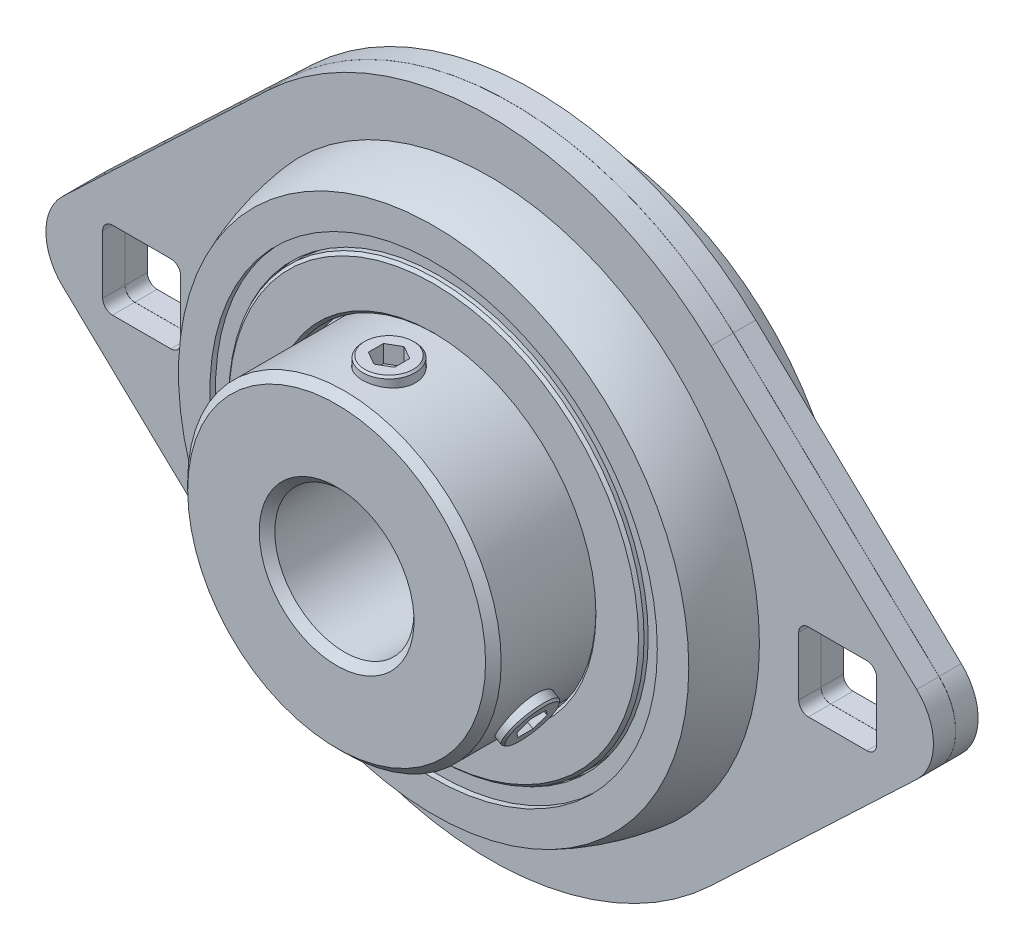
from build123d import *

# Parameters (mm, degrees)
CHAMFER3_SIZE           = 0.254
CHAMFER4_SIZE           = 0.254
CIRPATTERN1_COUNT       = 4
EXTRUDE1_DEPTH          = 2.032
EXTRUDE2_DEPTH          = 2.032
SKETCH6_W               = 7.112
SKETCH6_H               = 7.112
CUT_EXTRUDE1_DEPTH      = 16.99946
CUT_EXTRUDE1_DEPTH_BACK = 8.1501001
FILLET1_R               = 0.889
FILLET2_R               = 0.889
CHAMFER1_SIZE           = 0.7112
SKETCH7_W               = 2.413
SKETCH7_H               = 15.0622
CHAMFER2_SIZE           = 0.1778
CUT_EXTRUDE2_DEPTH      = 1.592865993
CIRPATTERN2_COUNT       = 2
CIRPATTERN2_ANGLE       = 120
CIRPATTERN3_COUNT       = 2
CIRPATTERN3_ANGLE       = 120


with BuildPart() as part:
    # Sketch1 → Revolve1 (revolve)
    with BuildSketch(Plane(origin=(0, 0, 0), x_dir=(0, 0, -1), z_dir=(1, 0, 0))):
        with BuildLine():
            Line((-15.99946, 6.35), (5.99948, 6.35))
            Line((5.99948, 6.35), (5.99948, 14.3002))
            Line((5.99948, 14.3002), (2.676895127, 14.3002))
            ThreePointArc((2.676895127, 14.3002), (0, 13.143865), (-2.676895127, 14.3002))
            Line((-2.676895127, 14.3002), (-15.99946, 14.3002))
            Line((-15.99946, 14.3002), (-15.99946, 6.35))
        make_face()
        with BuildLine():
            Line((0.00508, 29.3751), (0.00508, 22.692456694))
            ThreePointArc((0.00508, 22.692456694), (2.594293192, 22.486042447), (5.1181, 21.872013957))
            Line((5.1181, 21.872013957), (5.1181, 14.5542))
            Line((5.1181, 14.5542), (7.1501, 14.5542))
            Line((7.1501, 14.5542), (7.1501, 18.944888374))
            Line((7.1501, 18.944888374), (6.1341, 18.944888374))
            Line((6.1341, 18.944888374), (6.1341, 19.071888374))
            Line((6.1341, 19.071888374), (6.6421, 19.071888374))
            Line((6.6421, 19.071888374), (6.6421, 20.408451166))
            Line((6.6421, 20.408451166), (7.1501, 20.408451166))
            Line((7.1501, 20.408451166), (7.1501, 23.278359283))
            ThreePointArc((7.1501, 23.278359283), (4.641771595, 24.129812987), (2.03708, 24.611753333))
            Line((2.03708, 24.611753333), (2.03708, 29.3751))
            Line((2.03708, 29.3751), (0.00508, 29.3751))
        make_face()
        with BuildLine():
            Line((-2.03708, 29.3751), (-0.00508, 29.3751))
            Line((-0.00508, 29.3751), (-0.00508, 22.692456694))
            ThreePointArc((-0.00508, 22.692456694), (-2.594293192, 22.486042447), (-5.1181, 21.872013957))
            Line((-5.1181, 21.872013957), (-5.1181, 14.5542))
            Line((-5.1181, 14.5542), (-7.1501, 14.5542))
            Line((-7.1501, 14.5542), (-7.1501, 18.944888374))
            Line((-7.1501, 18.944888374), (-6.1341, 18.944888374))
            Line((-6.1341, 18.944888374), (-6.1341, 19.071888374))
            Line((-6.1341, 19.071888374), (-6.6421, 19.071888374))
            Line((-6.6421, 19.071888374), (-6.6421, 20.408451166))
            Line((-6.6421, 20.408451166), (-7.1501, 20.408451166))
            Line((-7.1501, 20.408451166), (-7.1501, 23.278359283))
            ThreePointArc((-7.1501, 23.278359283), (-4.641771595, 24.129812987), (-2.03708, 24.611753333))
            Line((-2.03708, 24.611753333), (-2.03708, 29.3751))
        make_face()
    revolve(axis=Axis((0, 0, 5.1181), (0, 0, -1)))

    # Chamfer3
    chamfer3_edges = [part.edges().sort_by_distance(p)[0] for p in [
        (0, -18.944888374, 7.1501),
        (0, -14.5542, 7.1501),
    ]]
    chamfer(chamfer3_edges, length=CHAMFER3_SIZE)

    # Chamfer4
    chamfer4_edges = [part.edges().sort_by_distance(p)[0] for p in [
        (0, -14.5542, -7.1501),
        (0, -18.944888374, -7.1501),
    ]]
    chamfer(chamfer4_edges, length=CHAMFER4_SIZE)

    # Sketch4 → Extrude1 (add)
    with BuildSketch(Plane.XY.offset(2.03708)):
        with BuildLine():
            Line((-20.202896864, 21.324620942), (-38.958083746, 3.556))
            ThreePointArc((-38.958083746, 3.556), (-40.4876, 0), (-38.958083746, -3.556))
            Line((-38.958083746, -3.556), (-20.202896864, -21.324620942))
            ThreePointArc((-20.202896864, -21.324620942), (-29.3751, 0), (-20.202896864, 21.324620942))
        make_face()
        with BuildLine():
            Line((20.202896864, -21.324620942), (38.958083746, -3.556))
            ThreePointArc((38.958083746, -3.556), (40.4876, 0), (38.958083746, 3.556))
            Line((38.958083746, 3.556), (20.202896864, 21.324620942))
            ThreePointArc((20.202896864, 21.324620942), (29.3751, 0), (20.202896864, -21.324620942))
        make_face()
    extrude(amount=-EXTRUDE1_DEPTH)

    # Sketch5 → Extrude2 (add)
    with BuildSketch(Plane(origin=(0, 0, -2.03708), x_dir=(-1, 0, 0), z_dir=(0, 0, -1))):
        with BuildLine():
            Line((20.202896864, 21.324620942), (38.958083746, 3.556))
            ThreePointArc((38.958083746, 3.556), (40.4876, 0), (38.958083746, -3.556))
            Line((38.958083746, -3.556), (20.202896864, -21.324620942))
            ThreePointArc((20.202896864, -21.324620942), (29.3751, 0), (20.202896864, 21.324620942))
        make_face()
        with BuildLine():
            Line((-20.202896864, -21.324620942), (-38.958083746, -3.556))
            ThreePointArc((-38.958083746, -3.556), (-40.4876, 0), (-38.958083746, 3.556))
            Line((-38.958083746, 3.556), (-20.202896864, 21.324620942))
            ThreePointArc((-20.202896864, 21.324620942), (-29.3751, 0), (-20.202896864, -21.324620942))
        make_face()
    extrude(amount=-EXTRUDE2_DEPTH)

    # Sketch6 → Cut-Extrude1 (cut, two sides)
    with BuildSketch(Plane.XY) as cut_extrude1_sk:
        with Locations((31.75, 0)):
            Rectangle(SKETCH6_W, SKETCH6_H)
        with Locations((-31.75, 0)):
            Rectangle(SKETCH6_W, SKETCH6_H)
    extrude(amount=CUT_EXTRUDE1_DEPTH, mode=Mode.SUBTRACT)
    extrude(cut_extrude1_sk.sketch, amount=-CUT_EXTRUDE1_DEPTH_BACK, mode=Mode.SUBTRACT)

    # Fillet1
    fillet1_edges = [part.edges().sort_by_distance(p)[0] for p in [
        (35.306, 3.556, -1.02108),
        (35.306, -3.556, -1.02108),
        (28.194, -3.556, -1.02108),
        (28.194, 3.556, -1.02108),
        (-28.194, -3.556, -1.02108),
        (-35.306, -3.556, -1.02108),
        (-35.306, 3.556, -1.02108),
        (-28.194, 3.556, -1.02108),
    ]]
    fillet(fillet1_edges, radius=FILLET1_R)

    # Fillet2
    fillet2_edges = [part.edges().sort_by_distance(p)[0] for p in [
        (35.306, 3.556, 1.02108),
        (35.306, -3.556, 1.02108),
        (28.194, -3.556, 1.02108),
        (28.194, 3.556, 1.02108),
        (-28.194, -3.556, 1.02108),
        (-35.306, -3.556, 1.02108),
        (-35.306, 3.556, 1.02108),
        (-28.194, 3.556, 1.02108),
    ]]
    fillet(fillet2_edges, radius=FILLET2_R)

    # Chamfer1
    chamfer1_edges = [part.edges().sort_by_distance(p)[0] for p in [
        (0, -14.3002, 15.99946),
        (0, -6.35, -5.99948),
        (0, -6.35, 15.99946),
    ]]
    chamfer(chamfer1_edges, length=CHAMFER1_SIZE)

    # Sketch7 → Cut-Revolve2 (revolve, cut)
    with BuildSketch(Plane(origin=(0, 0, 0), x_dir=(0, 0, -1), z_dir=(1, 0, 0))):
        with Locations((-12.42568, 7.5311)):
            Rectangle(SKETCH7_W, SKETCH7_H)
    cut_revolve2 = revolve(axis=Axis((0, 0, 11.21918), (0, 1, 0)), mode=Mode.SUBTRACT)

    # CirPattern2: Cut-Revolve2 ×2 about axis
    cirpattern2_axis = Axis((0, 0, 0), (0, 0, -1))
    for i in range(1, CIRPATTERN2_COUNT):
        add(cut_revolve2.rotate(cirpattern2_axis, i * CIRPATTERN2_ANGLE / (CIRPATTERN2_COUNT - 1)), mode=Mode.SUBTRACT)


with BuildPart() as body_2:
    # Sketch2 → Revolve2 (revolve)
    with BuildSketch(Plane(origin=(0, 0, 0), x_dir=(0, 0, -1), z_dir=(1, 0, 0))):
        with BuildLine():
            Line((-4.8006, 19.34083), (-2.676895127, 19.34083))
            ThreePointArc((-2.676895127, 19.34083), (0, 20.497165), (2.676895127, 19.34083))
            Line((2.676895127, 19.34083), (4.8006, 19.34083))
            Line((4.8006, 19.34083), (4.8006, 21.640592696))
            ThreePointArc((4.8006, 21.640592696), (-0.000244533, 22.37495581), (-4.8006, 21.637402552))
            Line((-4.8006, 21.637402552), (-4.8006, 19.34083))
        make_face()
    revolve(axis=Axis((0, 0, 5.1181), (0, 0, -1)))


with BuildPart() as body_3:
    # Sketch3 → Revolve3 (revolve)
    with BuildSketch(Plane(origin=(0, 0, 0), x_dir=(0, 0, -1), z_dir=(1, 0, 0))):
        with BuildLine():
            Line((0, 20.420965), (0, 13.220065))
            ThreePointArc((0, 13.220065), (3.60045, 16.820515), (0, 20.420965))
        make_face()
    revolve(axis=Axis((0, 20.420965, 0), (0, -1, 0)))


with BuildPart() as cirpattern1_1:
    # CirPattern1: pattern copy
    add(body_3.part.rotate(Axis((0, 0, 0), (0, 0, 1)), 1 * 360 / CIRPATTERN1_COUNT))


with BuildPart() as cirpattern1_2:
    # CirPattern1: pattern copy
    add(body_3.part.rotate(Axis((0, 0, 0), (0, 0, 1)), 2 * 360 / CIRPATTERN1_COUNT))


with BuildPart() as cirpattern1_3:
    # CirPattern1: pattern copy
    add(body_3.part.rotate(Axis((0, 0, 0), (0, 0, 1)), 3 * 360 / CIRPATTERN1_COUNT))


with BuildPart() as body_7:
    # Sketch8 → Revolve4 (revolve)
    with BuildSketch(Plane(origin=(0, 0, 0), x_dir=(0, 0, -1), z_dir=(1, 0, 0))):
        Polygon((-13.60678, 15.0622), (-13.60678, 7.097870034), (-13.334577569, 6.35), (-11.21918, 6.35), (-11.21918, 15.0622), (-12.015046667, 15.0622), (-12.810913333, 15.0622), align=None)
    revolve(axis=Axis((0, 6.35, 11.21918), (0, 1, 0)))

    # Chamfer2
    chamfer2_edges = [body_7.edges().sort_by_distance(p)[0] for p in [
        (0, 15.0622, 8.83158),
    ]]
    chamfer(chamfer2_edges, length=CHAMFER2_SIZE)

    # Sketch9 → Cut-Extrude2 (cut)
    with BuildSketch(Plane(origin=(0, 15.0622, 0), x_dir=(-1, 0, 0), z_dir=(0, 1, 0))):
        Polygon((0, 9.840698497), (1.1938, 10.529939249), (1.1938, 11.908420751), (0, 12.597661503), (-1.1938, 11.908420751), (-1.1938, 10.529939249), align=None)
    extrude(amount=-CUT_EXTRUDE2_DEPTH, mode=Mode.SUBTRACT)


with BuildPart() as cirpattern3_1:
    # CirPattern3: pattern copy
    add(body_7.part.rotate(Axis((0, 0, 0), (0, 0, -1)), 1 * CIRPATTERN3_ANGLE / (CIRPATTERN3_COUNT - 1)))


solid = Compound([part.part, body_2.part, body_3.part, cirpattern1_1.part, cirpattern1_2.part, cirpattern1_3.part, body_7.part, cirpattern3_1.part])
